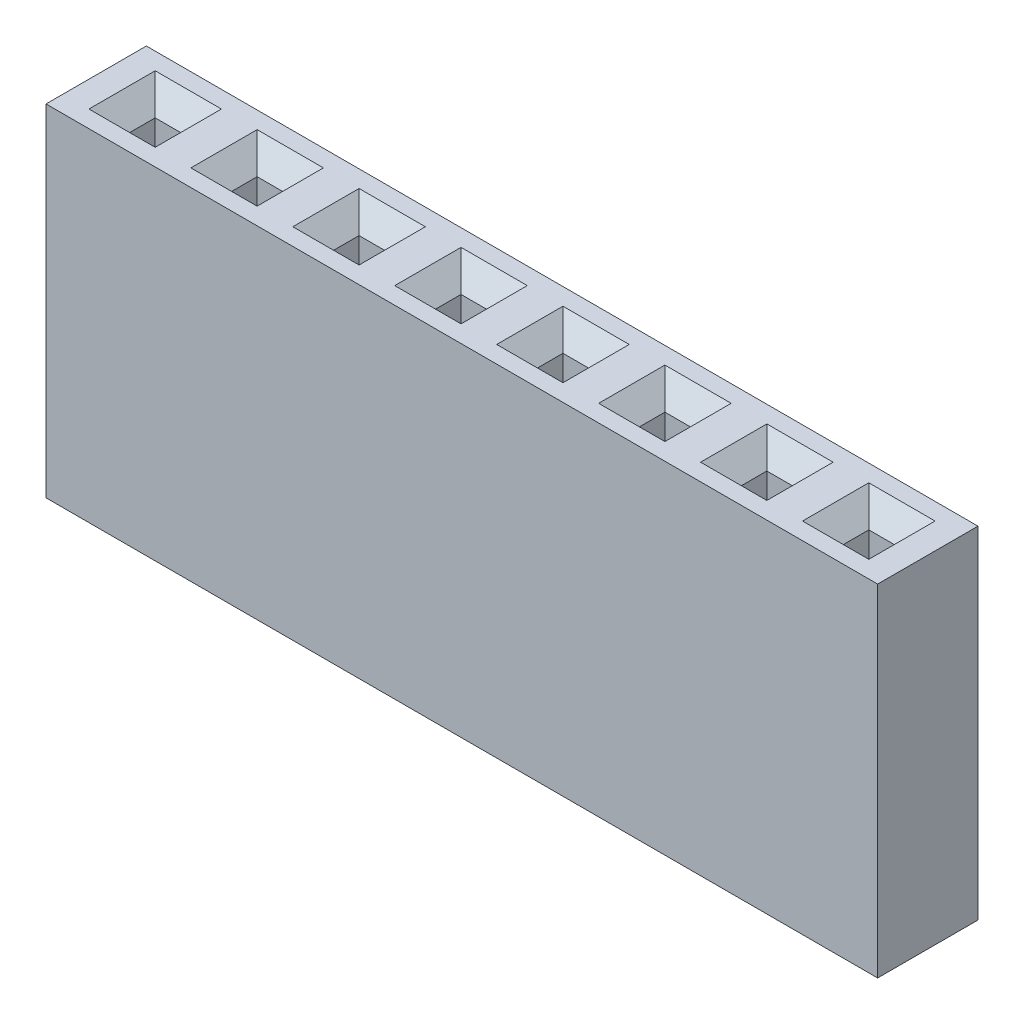
from build123d import *

# Parameters (mm, degrees)
SKETCH1_W                  = 20.72
SKETCH1_H                  = 2.5
BOSS_EXTRUDE1_DEPTH        = 8.5
SKETCH2_W                  = 0.635
SKETCH2_H                  = 0.635
CUT_EXTRUDE1_DEPTH         = 6.35
CHAMFER1_SIZE              = 0.508
LPATTERN1_COUNT            = 8
LPATTERN1_PITCH            = 2.54
CHAMFER1_OF_LPATTERN1_SIZE = 0.508


with BuildPart() as part:
    # Sketch1 → Boss-Extrude1 (new body)
    with BuildSketch(Plane(origin=(0, 0, 0), x_dir=(1, 0, 0), z_dir=(0, 1, 0))):
        with Locations((10.36, 1.25)):
            Rectangle(SKETCH1_W, SKETCH1_H)
    extrude(amount=BOSS_EXTRUDE1_DEPTH)

    # Sketch2 → Cut-Extrude1 (cut)
    with BuildSketch(Plane(origin=(0, 8.5, 0), x_dir=(1, 0, 0), z_dir=(0, 1, 0))):
        with Locations((1.47, 1.25)):
            Rectangle(SKETCH2_W, SKETCH2_H)
    cut_extrude1 = extrude(amount=-CUT_EXTRUDE1_DEPTH, mode=Mode.SUBTRACT)

    # Chamfer1
    chamfer1_edges = [part.edges().sort_by_distance(p)[0] for p in [
        (1.7875, 8.5, -1.25),
        (1.47, 8.5, -1.5675),
        (1.1525, 8.5, -1.25),
        (1.47, 8.5, -0.9325),
    ]]
    chamfer(chamfer1_edges, length=CHAMFER1_SIZE)

    # LPattern1: Cut-Extrude1 ×8
    with Locations(*[(i * LPATTERN1_PITCH, 0, 0) for i in range(1, LPATTERN1_COUNT)]):
        add(cut_extrude1, mode=Mode.SUBTRACT)

    # Chamfer1 of LPattern1
    chamfer1_of_lpattern1_edges = [part.edges().sort_by_distance(p)[0] for p in [
        (4.3275, 8.5, -1.25),
        (4.01, 8.5, -1.5675),
        (3.6925, 8.5, -1.25),
        (4.01, 8.5, -0.9325),
        (6.8675, 8.5, -1.25),
        (6.55, 8.5, -1.5675),
        (6.2325, 8.5, -1.25),
        (6.55, 8.5, -0.9325),
        (9.4075, 8.5, -1.25),
        (9.09, 8.5, -1.5675),
        (8.7725, 8.5, -1.25),
        (9.09, 8.5, -0.9325),
        (11.9475, 8.5, -1.25),
        (11.63, 8.5, -1.5675),
        (11.3125, 8.5, -1.25),
        (11.63, 8.5, -0.9325),
        (14.4875, 8.5, -1.25),
        (14.17, 8.5, -1.5675),
        (13.8525, 8.5, -1.25),
        (14.17, 8.5, -0.9325),
        (17.0275, 8.5, -1.25),
        (16.71, 8.5, -1.5675),
        (16.3925, 8.5, -1.25),
        (16.71, 8.5, -0.9325),
        (19.5675, 8.5, -1.25),
        (19.25, 8.5, -1.5675),
        (18.9325, 8.5, -1.25),
        (19.25, 8.5, -0.9325),
    ]]
    chamfer(chamfer1_of_lpattern1_edges, length=CHAMFER1_OF_LPATTERN1_SIZE)


solid = part.part
